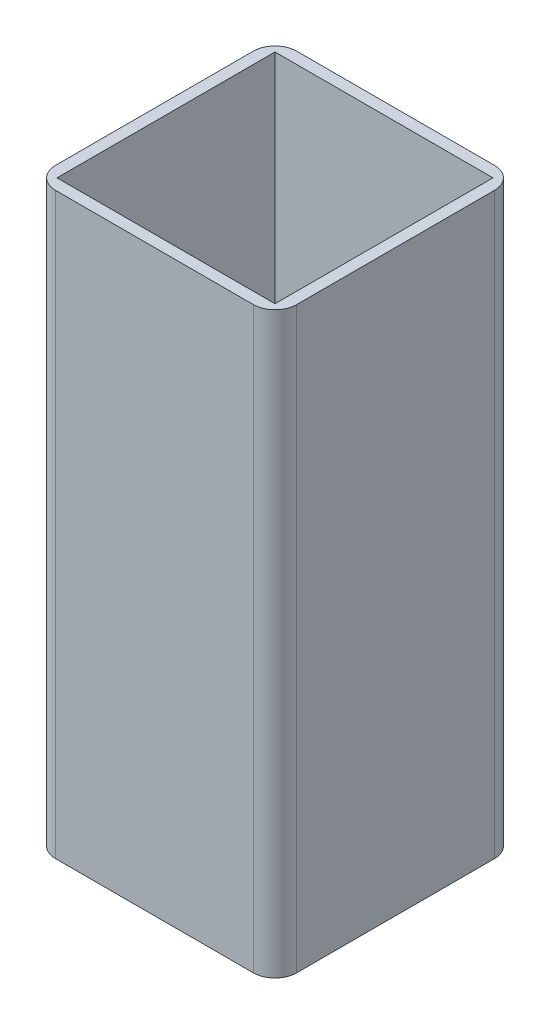
from build123d import *

# Parameters (mm, degrees)
SKETCH1_W           = 33.333333333
SKETCH1_H           = 33.333333333
SKETCH1_W_2         = 30.133333333
SKETCH1_H_2         = 30.133333333
BOSS_EXTRUDE1_DEPTH = 80
FILLET2_R           = 3
SCALE1_SCALE        = 7.5


with BuildPart() as part:
    # Sketch1 → Boss-Extrude1 (new body)
    with BuildSketch(Plane(origin=(0, 0, 0), x_dir=(1, 0, 0), z_dir=(0, 1, 0))):
        with Locations((16.666666666, 16.666666666)):
            Rectangle(SKETCH1_W, SKETCH1_H)
        with Locations((16.666666666, 16.666666666)):
            Rectangle(SKETCH1_W_2, SKETCH1_H_2, mode=Mode.SUBTRACT)
    extrude(amount=BOSS_EXTRUDE1_DEPTH)

    # Fillet2
    fillet2_edges = [part.edges().sort_by_distance(p)[0] for p in [
        (0, 40, -33.333333333),
        (33.333333333, 40, -33.333333333),
        (33.333333333, 40, 0),
        (0, 40, 0),
    ]]
    fillet(fillet2_edges, radius=FILLET2_R)


with BuildPart() as part_1:
    # Scale1: scaled about (16.666666667, 40, -16.666666667)
    add(part.part.scale(SCALE1_SCALE).moved(Location((-108.333333336, -260, 108.333333336))))


solid = part_1.part
